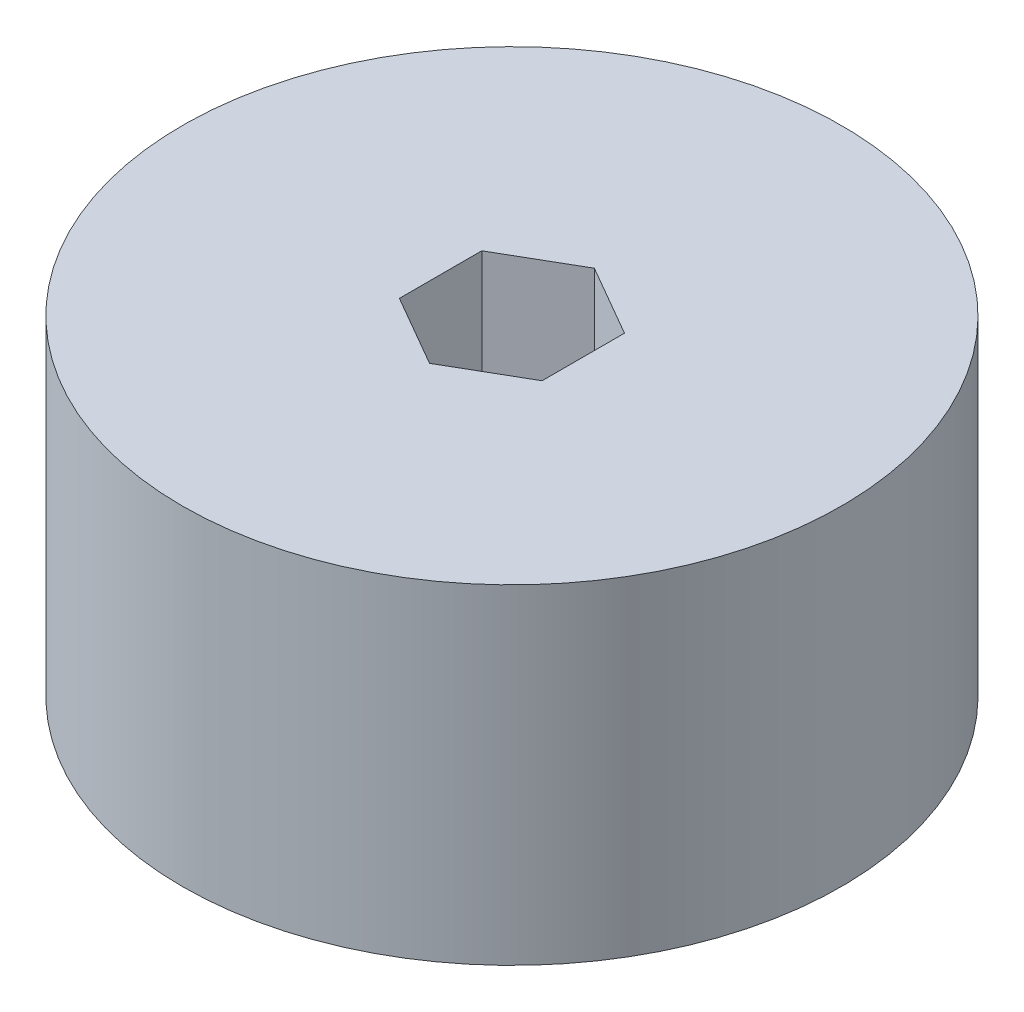
from build123d import *

# Parameters (mm, degrees)
SKETCH1_R           = 25.4
BOSS_EXTRUDE1_DEPTH = 25.4


with BuildPart() as part:
    # Sketch1 → Boss-Extrude1 (new body)
    with BuildSketch(Plane(origin=(0, 0, 0), x_dir=(1, 0, 0), z_dir=(0, 1, 0))):
        Circle(SKETCH1_R)
        Polygon((5.499261314, -3.175), (5.499261314, 3.175), (0, 6.35), (-5.499261314, 3.175), (-5.499261314, -3.175), (0, -6.35), align=None, mode=Mode.SUBTRACT)
    extrude(amount=BOSS_EXTRUDE1_DEPTH)


solid = part.part
